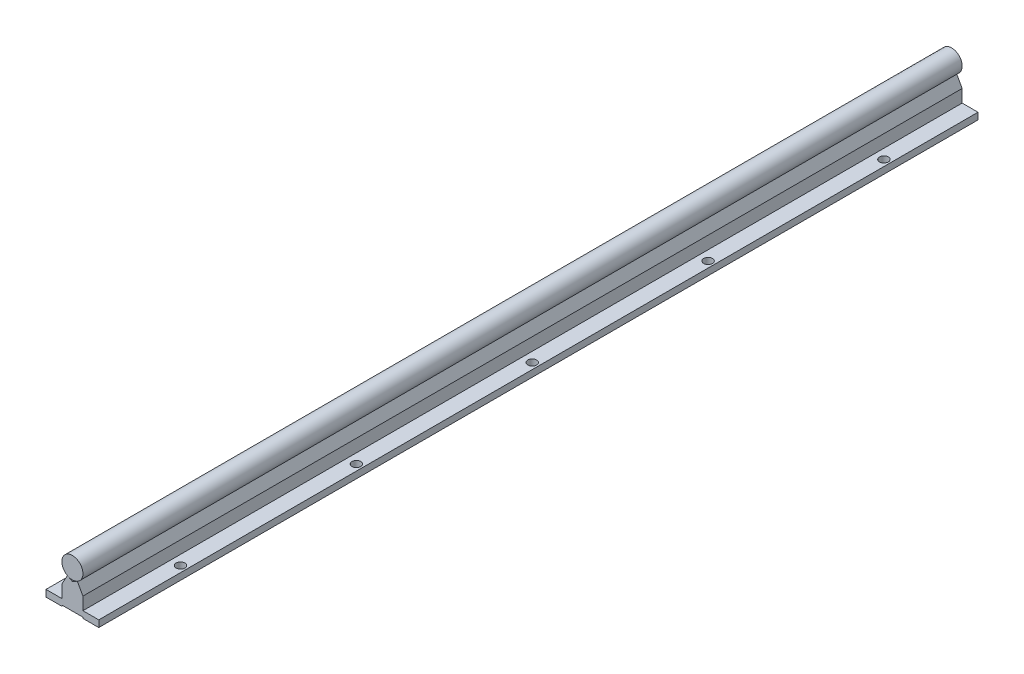
from build123d import *

# Parameters (mm, degrees)
SALIENTE_EXTRUIR1_DEPTH   = 500
CROQUIS1_R                = 6
SALIENTE_EXTRUIR1_2_DEPTH = 500
CROQUIS2_R                = 2.5
CORTAR_EXTRUIR1_DEPTH     = 3.8


with BuildPart() as part:
    # Croquis1 → Saliente-Extruir1 (new body)
    with BuildSketch(Plane.XY):
        Polygon((0, -6.8), (2.823529412, -5.294117647), (6, -11), (6, -18.2), (15, -18.2), (15, -22), (6, -22), (6, -21.4), (-6, -21.4), (-6, -22), (-15, -22), (-15, -18.2), (-6, -18.2), (-6, -11), (-2.823529412, -5.294117647), align=None)
    extrude(amount=SALIENTE_EXTRUIR1_DEPTH)

    # Croquis2 → Cortar-Extruir1 (cut)
    with BuildSketch(Plane(origin=(0, -18.2, 0), x_dir=(1, 0, 0), z_dir=(0, 1, 0))):
        with Locations((-11.5, -50)):
            Circle(CROQUIS2_R)
        with Locations((-11.5, -150)):
            Circle(CROQUIS2_R)
        with Locations((-11.5, -250)):
            Circle(CROQUIS2_R)
        with Locations((-11.5, -350)):
            Circle(CROQUIS2_R)
        with Locations((-11.5, -450)):
            Circle(CROQUIS2_R)
    cortar_extruir1 = extrude(amount=-CORTAR_EXTRUIR1_DEPTH, mode=Mode.SUBTRACT)

    # Simetría1: Cortar-Extruir1 across plane
    add(cortar_extruir1.mirror(Plane(origin=(0, 0, 0), x_dir=(0, 0, 1), z_dir=(1, 0, 0))), mode=Mode.SUBTRACT)


with BuildPart() as body_2:
    # Croquis1 → Saliente-Extruir1 2 (new body)
    with BuildSketch(Plane.XY):
        Circle(CROQUIS1_R)
    extrude(amount=SALIENTE_EXTRUIR1_2_DEPTH)


solid = Compound([part.part, body_2.part])
